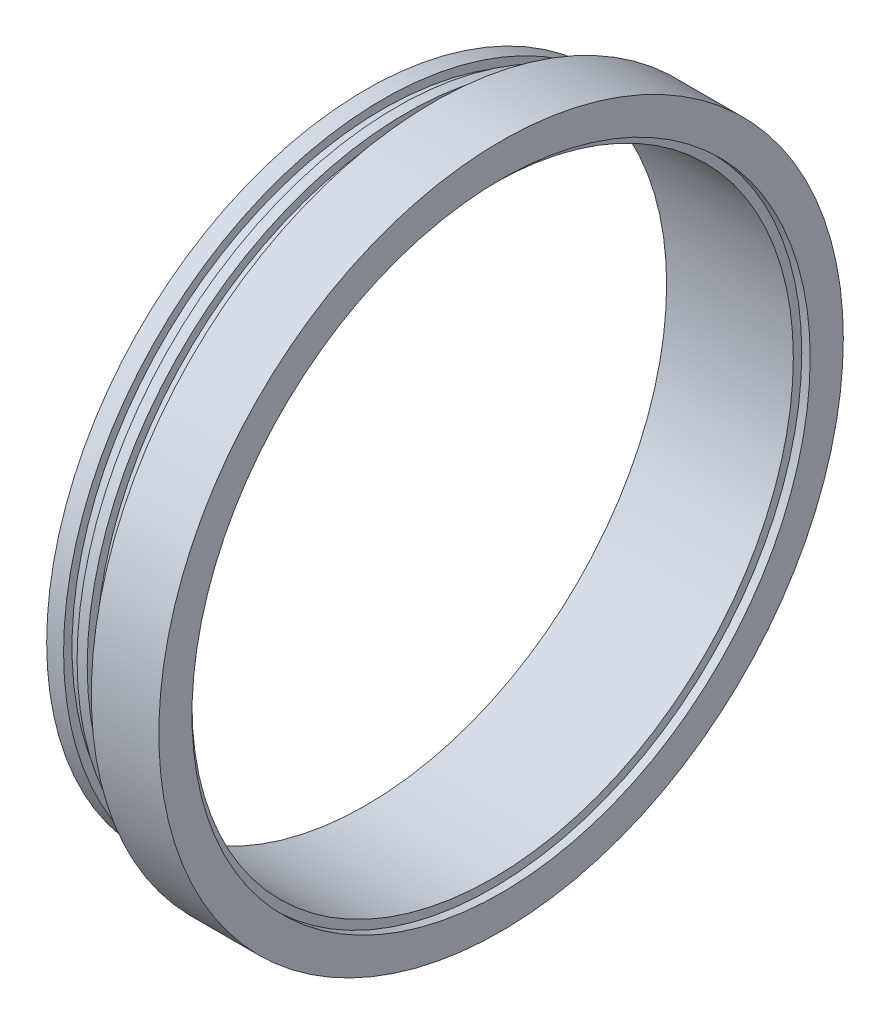
from build123d import *


with BuildPart() as part:
    # Sketch1 → Revolve1 (revolve)
    with BuildSketch(Plane.XY):
        Polygon((0, 89), (37.5, 89), (37.5, 91.5), (40, 91.5), (40, 101.3), (20, 101.3), (20, 94.5), (16, 94.5), (16, 92), (12, 92), (12, 94.5), (9, 94.5), (9, 92), (5, 92), (5, 94.5), (0, 94.5), align=None)
    revolve(axis=Axis((42, 0, 0), (-1, 0, 0)))


solid = part.part
